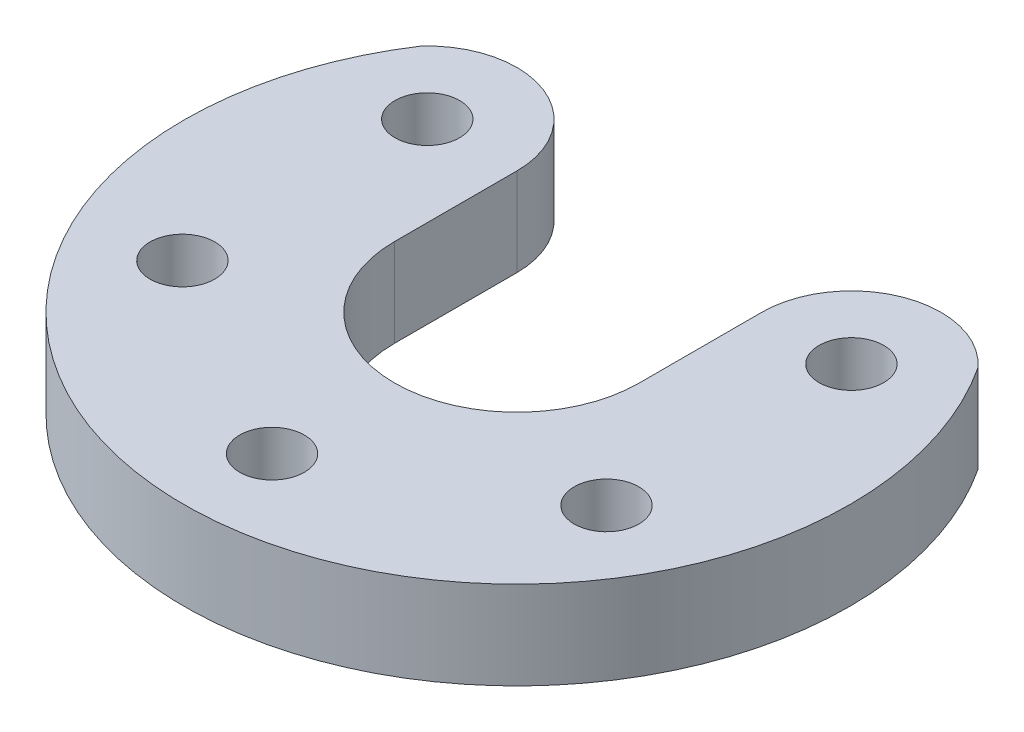
from build123d import *

# Parameters (mm, degrees)
SKETCH1_R           = 1.65
BOSS_EXTRUDE1_DEPTH = 4.5


with BuildPart() as part:
    # Sketch1 → Boss-Extrude1 (new body)
    with BuildSketch(Plane(origin=(0, 0, 0), x_dir=(1, 0, 0), z_dir=(0, 1, 0))):
        with BuildLine():
            Line((6.25, 6.25), (6.25, 0))
            ThreePointArc((6.25, 0), (0, -6.25), (-6.25, 0))
            Line((-6.25, 0), (-6.25, 6.25))
            ThreePointArc((-6.25, 6.25), (-9.179700773, 10.519130601), (-14.216868268, 9.320979382))
            ThreePointArc((-14.216868268, 9.320979382), (-14.722431864, 8.5), (-15.180639067, 7.651679391))
            ThreePointArc((-15.180639067, 7.651679391), (0, -17), (15.180639067, 7.651679391))
            ThreePointArc((15.180639067, 7.651679391), (14.722431864, 8.5), (14.216868268, 9.320979382))
            ThreePointArc((14.216868268, 9.320979382), (9.179700773, 10.519130601), (6.25, 6.25))
        make_face()
        with Locations((-10.825317547, -6.25)):
            Circle(SKETCH1_R, mode=Mode.SUBTRACT)
        with Locations((0, -12.5)):
            Circle(SKETCH1_R, mode=Mode.SUBTRACT)
        with Locations((10.825317547, -6.25)):
            Circle(SKETCH1_R, mode=Mode.SUBTRACT)
        with Locations((-10.825317547, 6.25)):
            Circle(SKETCH1_R, mode=Mode.SUBTRACT)
        with Locations((10.825317547, 6.25)):
            Circle(SKETCH1_R, mode=Mode.SUBTRACT)
    extrude(amount=BOSS_EXTRUDE1_DEPTH)


solid = part.part
